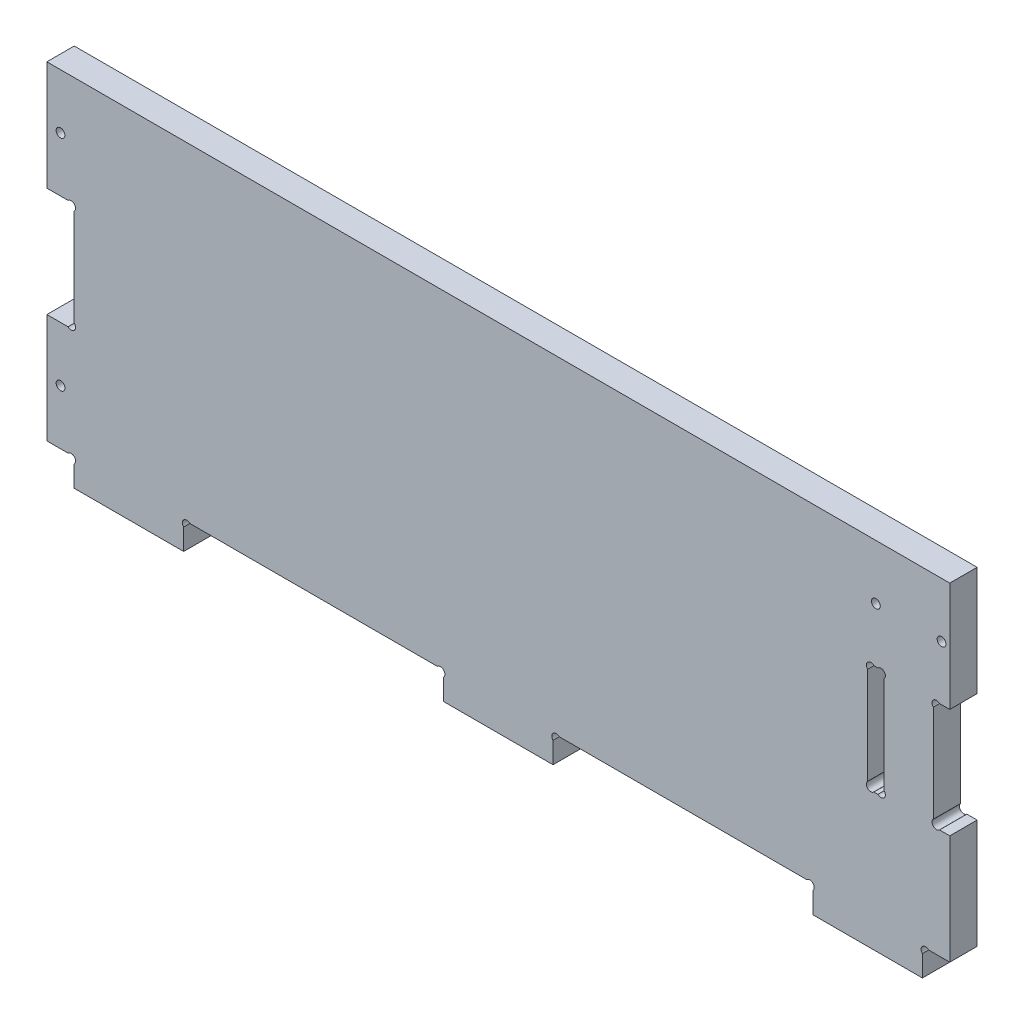
from build123d import *

# Parameters (mm, degrees)
ESQUISSE1_R      = 1.6
EXTRUSION1_DEPTH = 10


with BuildPart() as part:
    # Esquisse1 → Extrusion1 (new body)
    with BuildSketch(Plane.XY):
        with BuildLine():
            Line((326.2627417, 50), (330, 50))
            Line((330, 50), (330, 10))
            Line((330, 10), (322.2627417, 10))
            ThreePointArc((322.2627417, 10), (320, 10), (320, 7.7372583))
            Line((320, 7.7372583), (320, 0))
            Line((320, 0), (280, 0))
            Line((280, 0), (280, 7.7372583))
            ThreePointArc((280, 7.7372583), (280, 10), (277.7372583, 10))
            Line((277.7372583, 10), (187.2627417, 10))
            ThreePointArc((187.2627417, 10), (185, 10), (185, 7.7372583))
            Line((185, 7.7372583), (185, 0))
            Line((185, 0), (145, 0))
            Line((145, 0), (145, 7.7372583))
            ThreePointArc((145, 7.7372583), (145, 10), (142.7372583, 10))
            Line((142.7372583, 10), (52.2627417, 10))
            ThreePointArc((52.2627417, 10), (50, 10), (50, 7.7372583))
            Line((50, 7.7372583), (50, 0))
            Line((50, 0), (10, 0))
            Line((10, 0), (10, 7.7372583))
            ThreePointArc((10, 7.7372583), (10, 10), (7.7372583, 10))
            Line((7.7372583, 10), (0, 10))
            Line((0, 10), (0, 50))
            Line((0, 50), (7.7372583, 50))
            ThreePointArc((7.7372583, 50), (10, 50), (10, 52.2627417))
            Line((10, 52.2627417), (10, 87.7372583))
            ThreePointArc((10, 87.7372583), (10, 90), (7.7372583, 90))
            Line((7.7372583, 90), (0, 90))
            Line((0, 90), (0, 130))
            Line((0, 130), (330, 130))
            Line((330, 130), (330, 90))
            Line((330, 90), (326.2627417, 90))
            ThreePointArc((326.2627417, 90), (324, 90), (324, 87.7372583))
            Line((324, 87.7372583), (324, 52.2627417))
            ThreePointArc((324, 52.2627417), (324, 50), (326.2627417, 50))
        make_face()
        with Locations((5, 30)):
            Circle(ESQUISSE1_R, mode=Mode.SUBTRACT)
        with Locations(Location((5, 110, 0), (0, 0, 180))):  # turned: the seam where the file's is
            Circle(ESQUISSE1_R, mode=Mode.SUBTRACT)
        with Locations(Location((327, 110, 0), (0, 0, 180))):  # turned: the seam where the file's is
            Circle(ESQUISSE1_R, mode=Mode.SUBTRACT)
        with Locations((303, 110)):
            Circle(ESQUISSE1_R, mode=Mode.SUBTRACT)
        with BuildLine():
            Line((302.2627417, 50), (303.7372583, 50))
            ThreePointArc((303.7372583, 50), (306, 50), (306, 52.2627417))
            Line((306, 52.2627417), (306, 87.7372583))
            ThreePointArc((306, 87.7372583), (306, 90), (303.7372583, 90))
            Line((303.7372583, 90), (302.2627417, 90))
            ThreePointArc((302.2627417, 90), (300, 90), (300, 87.7372583))
            Line((300, 87.7372583), (300, 52.2627417))
            ThreePointArc((300, 52.2627417), (300, 50), (302.2627417, 50))
        make_face(mode=Mode.SUBTRACT)
    extrude(amount=EXTRUSION1_DEPTH)


solid = part.part
